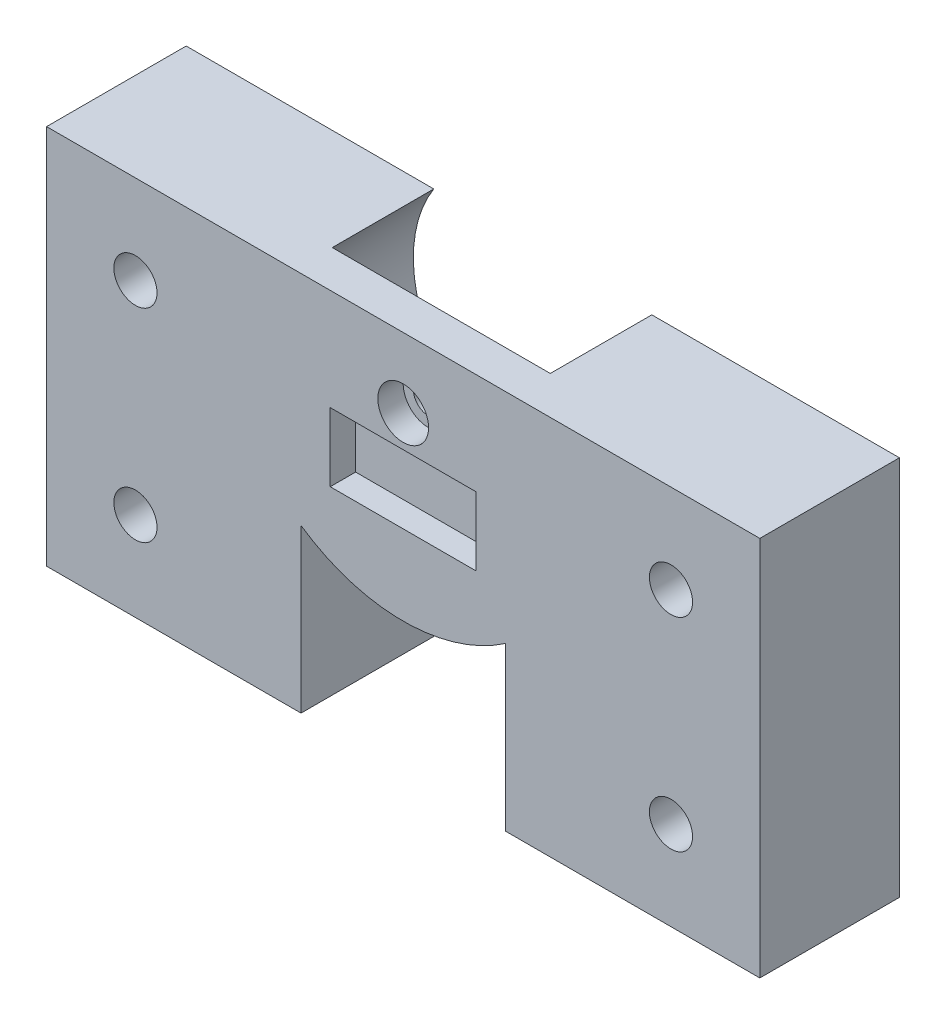
from build123d import *

# Parameters (mm, degrees)
BOSS_EXTRUDE1_DEPTH = 8
SKETCH3_W           = 56.2
SKETCH3_H           = 30
BOSS_EXTRUDE2_DEPTH = 3
SKETCH4_R           = 1.7
SKETCH4_R_2         = 1.2
CUT_EXTRUDE2_DEPTH  = 11
CUT_EXTRUDE3_DEPTH  = 8
SKETCH7_R           = 2
SKETCH7_W           = 11.5
SKETCH7_H           = 5.4
CUT_EXTRUDE4_DEPTH  = 2
CUT_EXTRUDE6_REACH  = 13


with BuildPart() as part:
    # Sketch1 → Boss-Extrude1 (new body)
    with BuildSketch(Plane.XY):
        with BuildLine():
            Line((19.509889407, 0), (0, 0))
            Line((0, 0), (0, -30))
            Line((0, -30), (56.2, -30))
            Line((56.2, -30), (56.2, 0))
            Line((56.2, 0), (36.690110593, 0))
            Line((36.690110593, 0), (35.825930365, 0))
            ThreePointArc((35.825930365, 0), (34.325930365, -1.5), (35.825930365, -3))
            Line((35.825930365, -3), (37.988882647, -3))
            ThreePointArc((37.988882647, -3), (26.465465751, -15.568182447), (19.509889407, 0))
        make_face()
    extrude(amount=BOSS_EXTRUDE1_DEPTH)

    # Sketch3 → Boss-Extrude2 (add)
    with BuildSketch(Plane.XY.offset(8)):
        with Locations((28.1, -15)):
            Rectangle(SKETCH3_W, SKETCH3_H)
    extrude(amount=BOSS_EXTRUDE2_DEPTH)

    # Sketch4 → Cut-Extrude2 (cut)
    with BuildSketch(Plane(origin=(0, 0, 0), x_dir=(-1, 0, 0), z_dir=(0, 0, -1))):
        with Locations((-49.2, -7)):
            Circle(SKETCH4_R)
        with Locations((-7, -7)):
            Circle(SKETCH4_R)
        with Locations((-7, -23)):
            Circle(SKETCH4_R)
        with Locations((-49.2, -23)):
            Circle(SKETCH4_R)
        with Locations((-28.1, -5.5)):
            Circle(SKETCH4_R_2)
    extrude(amount=-CUT_EXTRUDE2_DEPTH, mode=Mode.SUBTRACT)

    # Sketch5 → Cut-Extrude3 (cut)
    with BuildSketch(Plane(origin=(0, 0, 0), x_dir=(-1, 0, 0), z_dir=(0, 0, -1))):
        with BuildLine():
            Line((-19.509889407, 0), (-36.690110593, 0))
            ThreePointArc((-36.690110593, 0), (-28.1, -15.7), (-19.509889407, 0))
        make_face()
    extrude(amount=-CUT_EXTRUDE3_DEPTH, mode=Mode.SUBTRACT)

    # Sketch7 → Cut-Extrude4 (cut)
    with BuildSketch(Plane.XY.offset(11)):
        with Locations((28.1, -5.5)):
            Circle(SKETCH7_R)
        with Locations((28.1, -10.7)):
            Rectangle(SKETCH7_W, SKETCH7_H)
    extrude(amount=-CUT_EXTRUDE4_DEPTH, mode=Mode.SUBTRACT)

    # Sketch9 → Cut-Extrude6 (cut, up to next)
    with BuildSketch(Plane.XY, mode=Mode.PRIVATE) as cut_extrude6_sk1:
        with BuildLine():
            Line((36.15, -30), (36.15, -17.197756195))
            ThreePointArc((36.15, -17.197756195), (28.1, -19.7), (20.05, -17.197756195))
            Line((20.05, -17.197756195), (20.05, -30))
            Line((20.05, -30), (36.15, -30))
        make_face()
    cut_extrude6_tool1 = extrude(cut_extrude6_sk1.sketch, amount=CUT_EXTRUDE6_REACH, mode=Mode.PRIVATE) & part.part
    add(cut_extrude6_tool1.solids().sort_by_distance((28.1, -24.424534, 0))[0], mode=Mode.SUBTRACT)


solid = part.part
